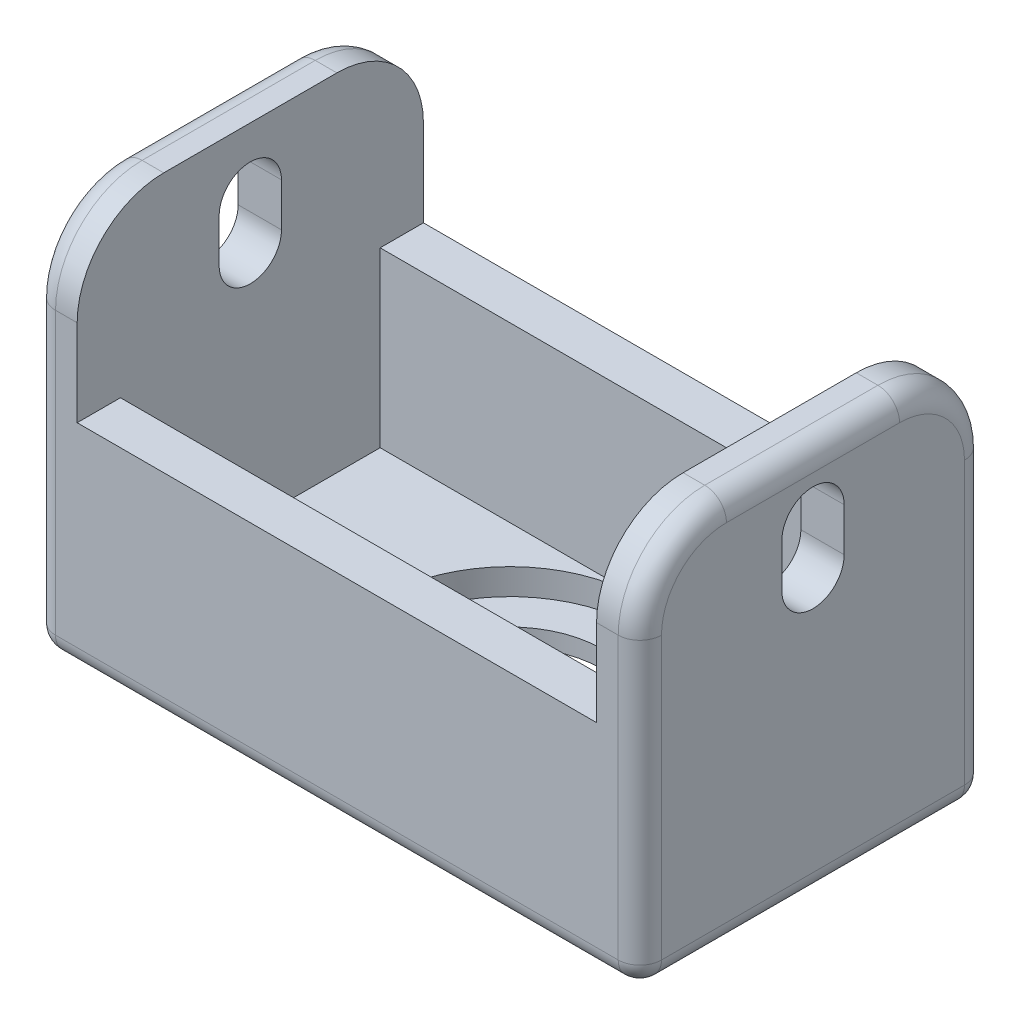
from build123d import *

# Parameters (mm, degrees)
SKETCH1_W           = 44.45
SKETCH1_H           = 25.4
BOSS_EXTRUDE1_DEPTH = 28.575
SHELL1_T            = -3.175
SKETCH2_W           = 38.1
SKETCH2_H           = 12.7
CUT_EXTRUDE1_DEPTH  = 26.4
CUT_EXTRUDE2_DEPTH  = 45.45
CUT_EXTRUDE3_DEPTH  = 4.175
FILLET1_R           = 6.35
FILLET2_R           = 1.5875
SKETCH6_R           = 9.525
CUT_EXTRUDE4_DEPTH  = 1.905


with BuildPart() as part:
    # Sketch1 → Boss-Extrude1 (new body)
    with BuildSketch(Plane(origin=(0, 0, 0), x_dir=(1, 0, 0), z_dir=(0, 1, 0))):
        with Locations((22.225, 12.7)):
            Rectangle(SKETCH1_W, SKETCH1_H)
    extrude(amount=BOSS_EXTRUDE1_DEPTH)

    # Shell1
    shell1_openings = [part.faces().sort_by_distance(p)[0] for p in [
        (22.225, 28.575, -12.7),
    ]]
    offset(amount=SHELL1_T, openings=shell1_openings, kind=Kind.INTERSECTION)

    # Sketch2 → Cut-Extrude1 (cut, through all)
    with BuildSketch(Plane.XY):
        with Locations((22.225, 22.225)):
            Rectangle(SKETCH2_W, SKETCH2_H)
    extrude(amount=-CUT_EXTRUDE1_DEPTH, mode=Mode.SUBTRACT)

    # Sketch3 → Cut-Extrude2 (cut, through all)
    with BuildSketch(Plane.ZY):
        with BuildLine():
            Line((-10.414, 23.8125), (-10.414, 20.6375))
            ThreePointArc((-10.414, 20.6375), (-12.7, 18.3515), (-14.986, 20.6375))
            Line((-14.986, 20.6375), (-14.986, 23.8125))
            ThreePointArc((-14.986, 23.8125), (-12.7, 26.0985), (-10.414, 23.8125))
        make_face()
    extrude(amount=-CUT_EXTRUDE2_DEPTH, mode=Mode.SUBTRACT)

    # Sketch5 → Cut-Extrude3 (cut, through all)
    with BuildSketch(Plane(origin=(0, 3.175, 0), x_dir=(1, 0, 0), z_dir=(0, 1, 0))):
        with BuildLine():
            Line((25.199729326, 6.5913), (19.250270674, 6.5913))
            ThreePointArc((19.250270674, 6.5913), (22.225, 19.4945), (25.199729326, 6.5913))
        make_face()
    extrude(amount=-CUT_EXTRUDE3_DEPTH, mode=Mode.SUBTRACT)

    # Fillet1
    fillet1_edges = [part.edges().sort_by_distance(p)[0] for p in [
        (42.8625, 28.575, -25.4),
        (1.5875, 28.575, -25.4),
        (42.8625, 28.575, 0),
        (1.5875, 28.575, 0),
    ]]
    fillet(fillet1_edges, radius=FILLET1_R)

    # Fillet2
    fillet2_edges = [part.edges().sort_by_distance(p)[0] for p in [
        (44.45, 26.715128061, -1.859871939),
        (44.45, 26.715128061, -23.540128061),
        (22.225, 0, -25.4),
        (44.45, 0, -12.7),
        (22.225, 0, 0),
        (0, 0, -12.7),
        (0, 28.575, -12.7),
        (0, 11.1125, 0),
        (0, 11.1125, -25.4),
        (0, 26.715128061, -1.859871939),
        (0, 26.715128061, -23.540128061),
        (44.45, 11.1125, -25.4),
        (44.45, 11.1125, 0),
        (44.45, 28.575, -12.7),
    ]]
    fillet(fillet2_edges, radius=FILLET2_R)

    # Sketch6 → Cut-Extrude4 (cut)
    with BuildSketch(Plane(origin=(0, 3.175, 0), x_dir=(1, 0, 0), z_dir=(0, 1, 0))):
        with Locations((22.225, 12.7)):
            Circle(SKETCH6_R)
    extrude(amount=-CUT_EXTRUDE4_DEPTH, mode=Mode.SUBTRACT)


solid = part.part
